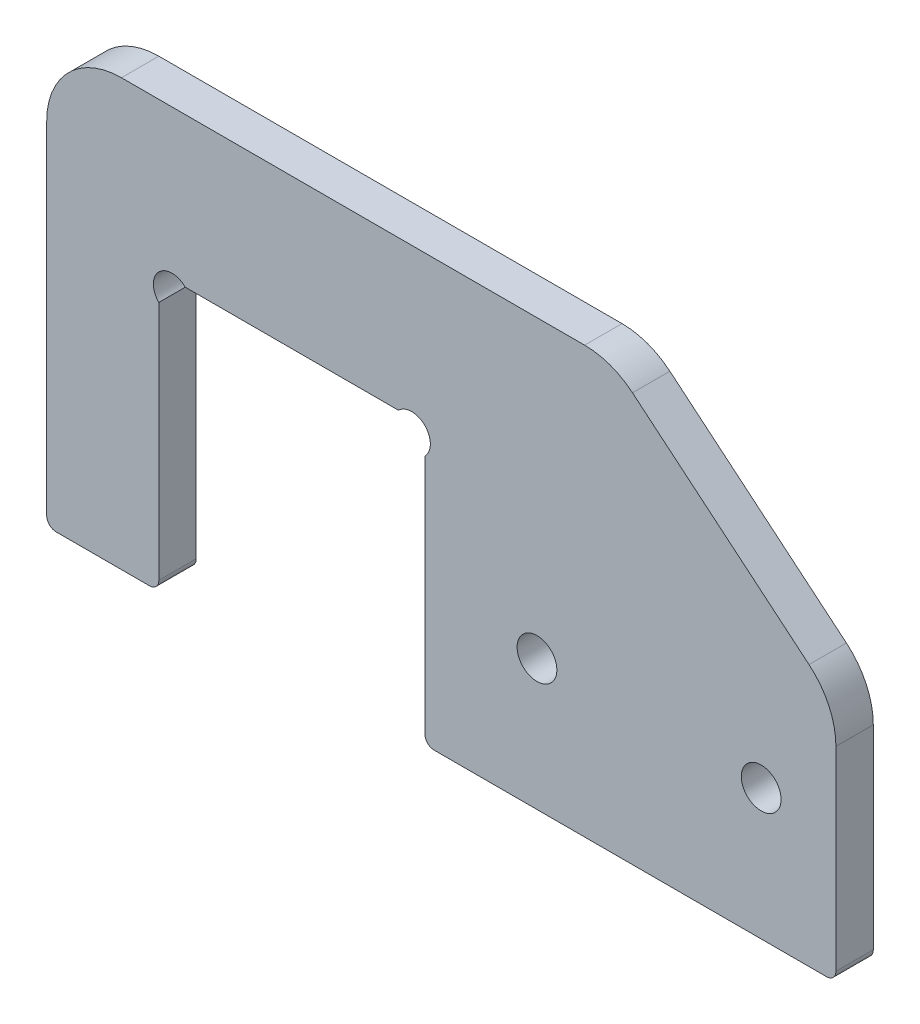
from build123d import *

# Parameters (mm, degrees)
BOSS_EXTRUDE1_DEPTH     = 6.35
F_1_4_CLEARANCE_HOLE1_D = 6.7564
CUT_EXTRUDE1_DEPTH      = 7.35
FILLET1_R               = 1.5875
FILLET2_R               = 12.7
SKETCH7_R               = 3.175
CUT_EXTRUDE2_DEPTH      = 7.35


with BuildPart() as part:
    # Sketch3 → Boss-Extrude1 (new body)
    with BuildSketch(Plane.XY):
        Polygon((0, 0), (0, 72.39), (-134.112, 72.39), (-134.112, 0), (-115.062, 0), (-115.062, 46.99), (-69.85, 46.99), (-69.85, 0), align=None)
    extrude(amount=BOSS_EXTRUDE1_DEPTH)

    # 1/4 Clearance Hole1 (through all)
    with Locations(Plane.XY.offset(6.35)):
        with Locations((-50.8, 22.225), (-12.7, 22.225)):
            Hole(F_1_4_CLEARANCE_HOLE1_D / 2)

    # Sketch6 → Cut-Extrude1 (cut, through all)
    with BuildSketch(Plane.XY.offset(6.35)):
        Polygon((0, 72.39), (0, 40.64), (-38.1, 72.39), align=None)
    extrude(amount=-CUT_EXTRUDE1_DEPTH, mode=Mode.SUBTRACT)

    # Fillet1
    fillet1_edges = [part.edges().sort_by_distance(p)[0] for p in [
        (-69.85, 0, 3.175),
        (-115.062, 0, 3.175),
        (-134.112, 0, 3.175),
        (0, 0, 3.175),
    ]]
    fillet(fillet1_edges, radius=FILLET1_R)

    # Fillet2
    fillet2_edges = [part.edges().sort_by_distance(p)[0] for p in [
        (-134.112, 72.39, 3.175),
        (-38.1, 72.39, 3.175),
        (0, 40.64, 3.175),
    ]]
    fillet(fillet2_edges, radius=FILLET2_R)

    # Sketch7 → Cut-Extrude2 (cut, through all)
    with BuildSketch(Plane.XY.offset(6.35)):
        with Locations((-112.81693597, 44.74493597)):
            Circle(SKETCH7_R)
        with Locations((-72.09506403, 44.74493597)):
            Circle(SKETCH7_R)
    extrude(amount=-CUT_EXTRUDE2_DEPTH, mode=Mode.SUBTRACT)


solid = part.part
